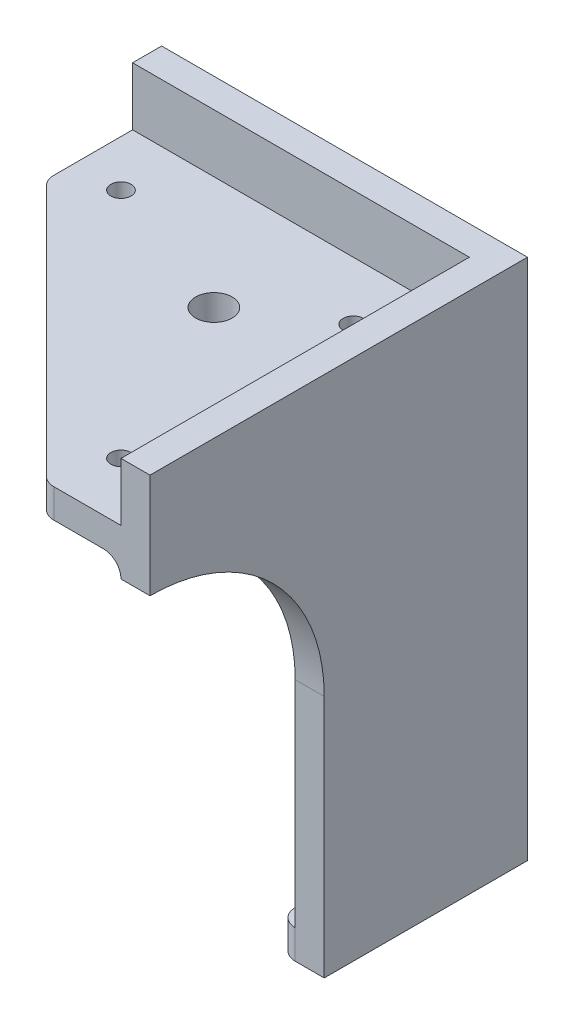
from build123d import *

# Parameters (mm, degrees)
SALIENTE_EXTRUIR1_DEPTH = 5
CROQUIS2_W              = 5
CROQUIS2_H              = 90
SALIENTE_EXTRUIR2_DEPTH = 60
CORTAR_EXTRUIR1_DEPTH   = 5
SALIENTE_EXTRUIR3_DEPTH = 5
REDONDEO1_R             = 3
CROQUIS5_W              = 58
CROQUIS5_H              = 5
SALIENTE_EXTRUIR4_DEPTH = 60
CORTAR_EXTRUIR2_DEPTH   = 5
REDONDEO2_R             = 3
REDONDEO3_R             = 3
CROQUIS7_R              = 1.75
CROQUIS7_R_2            = 3.15
CORTAR_EXTRUIR3_DEPTH   = 5


with BuildPart() as part:
    # Croquis1 → Saliente-Extruir1 (new body)
    with BuildSketch(Plane.XY):
        with BuildLine():
            Line((-63, 0), (0, 0))
            Line((0, 0), (0, -90))
            Line((0, -90), (-33, -90))
            Line((-33, -90), (-33, -48))
            ThreePointArc((-33, -48), (-41.786797, -26.786797), (-63, -18))
            Line((-63, -18), (-63, 0))
        make_face()
    extrude(amount=SALIENTE_EXTRUIR1_DEPTH)

    # Croquis2 → Saliente-Extruir2 (add)
    with BuildSketch(Plane.XY.offset(5)):
        with Locations((-2.5, -45)):
            Rectangle(CROQUIS2_W, CROQUIS2_H)
    extrude(amount=SALIENTE_EXTRUIR2_DEPTH)

    # Croquis3 → Cortar-Extruir1 (cut)
    with BuildSketch(Plane(origin=(0, 0, 0), x_dir=(0, 0, -1), z_dir=(1, 0, 0))):
        with BuildLine():
            Line((-65, -90), (-35, -90))
            Line((-35, -90), (-35, -48))
            ThreePointArc((-35, -48), (-43.786797, -26.786797), (-65, -18))
            Line((-65, -18), (-65, -90))
        make_face()
    extrude(amount=-CORTAR_EXTRUIR1_DEPTH, mode=Mode.SUBTRACT)

    # Croquis4 → Saliente-Extruir3 (add)
    with BuildSketch(Plane.XZ.offset(90)):
        Polygon((-33, 8), (-8, 8), (-8, 35), (-5, 35), (-5, 5), (-33, 5), align=None)
    extrude(amount=-SALIENTE_EXTRUIR3_DEPTH)

    # Redondeo1
    redondeo1_edges = [part.edges().sort_by_distance(p)[0] for p in [
        (-33, -87.5, 8),
        (-8, -87.5, 35),
    ]]
    fillet(redondeo1_edges, radius=REDONDEO1_R)

    # Croquis5 → Saliente-Extruir4 (add)
    with BuildSketch(Plane.XY.offset(5)):
        with Locations((-34, -12.5)):
            Rectangle(CROQUIS5_W, CROQUIS5_H)
    extrude(amount=SALIENTE_EXTRUIR4_DEPTH)

    # Croquis6 → Cortar-Extruir2 (cut)
    with BuildSketch(Plane(origin=(0, -10, 0), x_dir=(1, 0, 0), z_dir=(0, 1, 0))):
        Polygon((-63, -19.817641), (-17.817641, -65), (-63, -65), align=None)
    extrude(amount=-CORTAR_EXTRUIR2_DEPTH, mode=Mode.SUBTRACT)

    # Redondeo2
    redondeo2_edges = [part.edges().sort_by_distance(p)[0] for p in [
        (-63, -12.5, 19.817641),
        (-17.817641, -12.5, 65),
    ]]
    fillet(redondeo2_edges, radius=REDONDEO2_R)

    # Redondeo3
    redondeo3_edges = [part.edges().sort_by_distance(p)[0] for p in [
        (-34, -15, 5),
        (-5, -15, 35),
        (-5, -50, 5),
    ]]
    fillet(redondeo3_edges, radius=REDONDEO3_R)

    # Croquis7 → Cortar-Extruir3 (cut)
    with BuildSketch(Plane(origin=(0, -10, 0), x_dir=(1, 0, 0), z_dir=(0, 1, 0))):
        with Locations((-15, -55)):
            Circle(CROQUIS7_R)
        with Locations((-15, -15)):
            Circle(CROQUIS7_R)
        with Locations((-55, -15)):
            Circle(CROQUIS7_R)
        with Locations((-29.5, -24.5)):
            Circle(CROQUIS7_R_2)
    extrude(amount=-CORTAR_EXTRUIR3_DEPTH, mode=Mode.SUBTRACT)


solid = part.part
